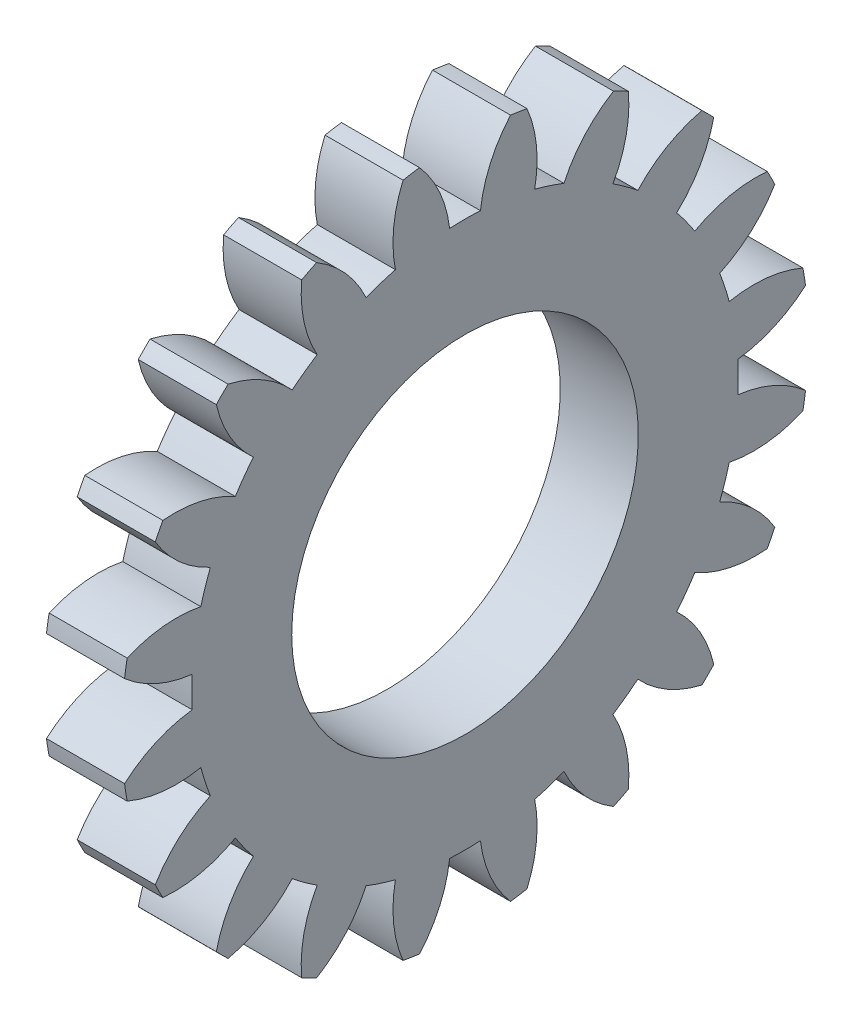
from build123d import *

# Parameters (mm, degrees)
BASPROSKE_W        = 5
BASPROSKE_H        = 22
TOOTHCUT_DEPTH     = 32.511902513
TEETHCUTS_COUNT    = 20
TEETHCUTS_ANGLE    = 342
BORSKE_R           = 0.5
BORE_DEPTH         = 50.0000508
SKETCH1_R          = 11.1
CUT_EXTRUDE1_DEPTH = 10


with BuildPart() as part:
    # BasProSke → Base-Revolve (revolve)
    with BuildSketch(Plane(origin=(0, 0, 0), x_dir=(1, 0, 0), z_dir=(0, 1, 0)), mode=Mode.PRIVATE) as base_revolve_sk:
        with Locations((2.5, 11)):
            Rectangle(BASPROSKE_W, BASPROSKE_H)
    revolve(base_revolve_sk.sketch.rotate(Axis((-10, 0, 0), (1, 0, 0)), 180), axis=Axis((-10, 0, 0), (1, 0, 0)))

    # TooCutSke → ToothCut (cut, through all)
    with BuildSketch(Plane(origin=(0, 0, 0), x_dir=(0, 0, -1), z_dir=(1, 0, 0))):
        with BuildLine():
            ThreePointArc((0.986171591, 17.471189616), (0, 17.499), (-0.986171591, 17.471189616))
            ThreePointArc((-0.986171591, 17.471189616), (-1.626916196, 19.798789858), (-2.932850173, 21.829260982))
            ThreePointArc((-2.932850173, 21.829260982), (0, 22.0254), (2.932850173, 21.829260982))
            ThreePointArc((2.932850173, 21.829260982), (1.626916196, 19.798789858), (0.986171591, 17.471189616))
        make_face()
    toothcut = extrude(amount=TOOTHCUT_DEPTH, mode=Mode.SUBTRACT)

    # TeethCuts: ToothCut ×20 about axis
    teethcuts_axis = Axis((-10, 0, 0), (1, 0, 0))
    for i in range(1, TEETHCUTS_COUNT):
        add(toothcut.rotate(teethcuts_axis, i * TEETHCUTS_ANGLE / (TEETHCUTS_COUNT - 1)), mode=Mode.SUBTRACT)

    # BorSke → Bore (cut, symmetric)
    with BuildSketch(Plane(origin=(0, 0, 0), x_dir=(0, 0, -1), z_dir=(1, 0, 0))):
        with Locations(Location((0, 0, 0), (0, 0, 180))):
            Circle(BORSKE_R)
    extrude(amount=BORE_DEPTH, both=True, mode=Mode.SUBTRACT)

    # Sketch1 → Cut-Extrude1 (cut)
    with BuildSketch(Plane.ZY):
        Circle(SKETCH1_R)
    extrude(amount=-CUT_EXTRUDE1_DEPTH, mode=Mode.SUBTRACT)


solid = part.part
